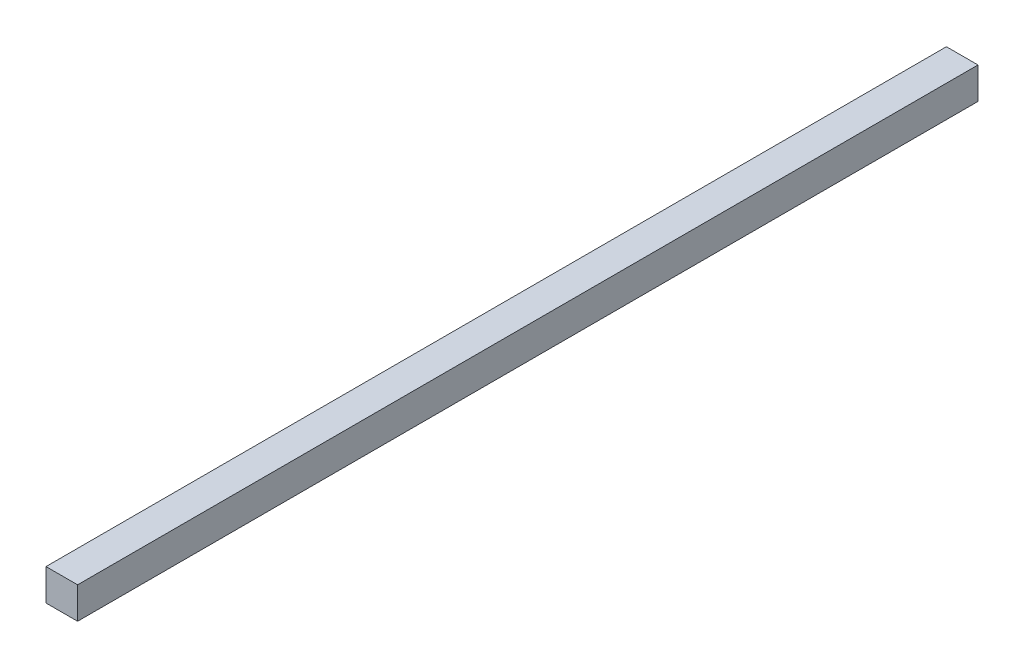
from build123d import *

# Parameters (mm, degrees)
SKETCH1_W      = 20
SKETCH1_H      = 570
EXTRUDE1_DEPTH = 20


with BuildPart() as part:
    # Sketch1 → Extrude1 (new body)
    with BuildSketch(Plane(origin=(0, 0, 0), x_dir=(1, 0, 0), z_dir=(0, 1, 0))):
        Rectangle(SKETCH1_W, SKETCH1_H)
    extrude(amount=EXTRUDE1_DEPTH)


solid = part.part
